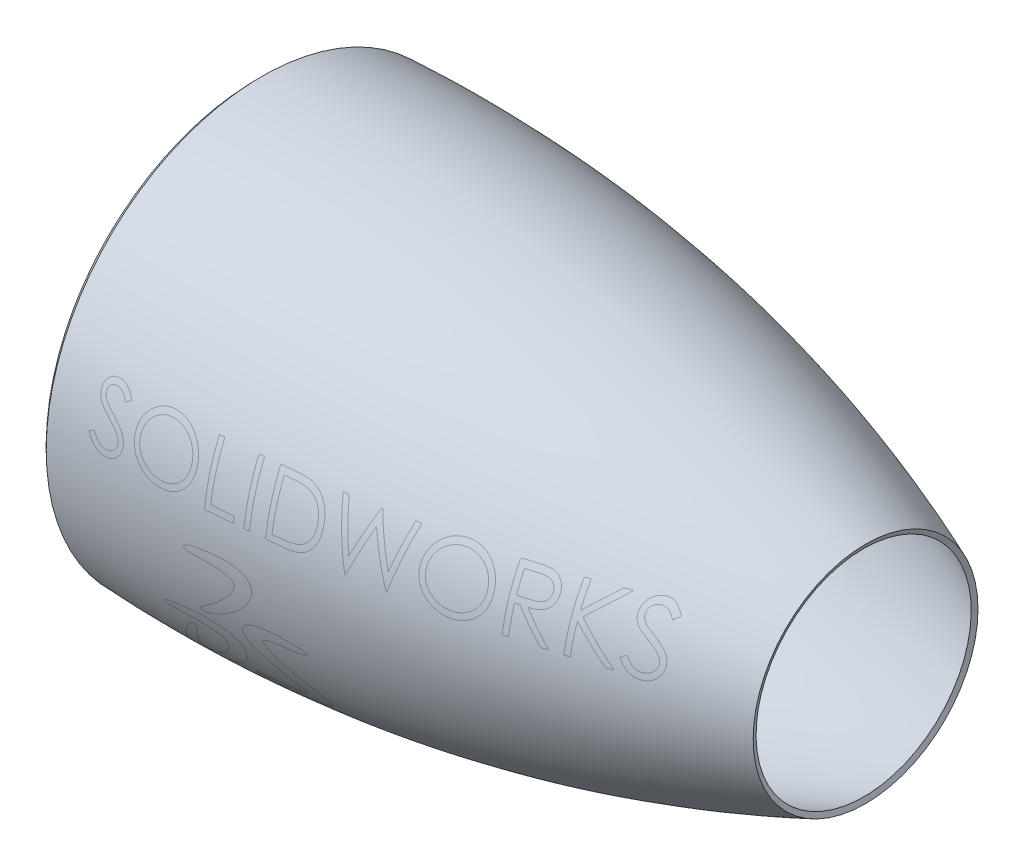
from build123d import *

# Parameters (mm, degrees)
ESPESSAMENTO1_T1 = 5


with BuildPart() as body_1:
    # Superf_cie-Revolu_o1: a surface, the sketch's curves turned about an axis
    with BuildLine(Plane.XY, mode=Mode.PRIVATE) as superf_cie_revolu_o1_1_path:
        Line((59.57343479, 190), (34.57343479, 190))
        Line((34.57343479, 190), (25, 180))
        Line((25, 180), (0, 180))
        add(Edge.make_bspline(
            [(0, 180), (-16.460029113, 193.295986939), (0, 207.237457751)],
            knots=[0, 0, 0, 1, 1, 1], degree=2))
        add(Edge.make_bspline(
            [(0, 207.237457751), (302.132873789, 221.273179142), (580, 108)],
            knots=[0, 0, 0, 1, 1, 1], degree=2))
    superf_cie_revolu_o1_1 = Shell.revolve(superf_cie_revolu_o1_1_path.wire(), 360, Axis((702.79266214, 0, 0), (-1, 0, 0)))
    add(Solid.thicken(superf_cie_revolu_o1_1, ESPESSAMENTO1_T1))


solid = body_1.part
